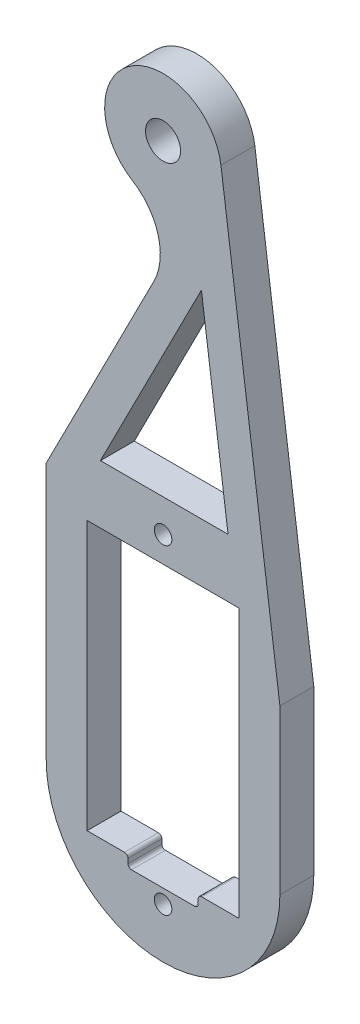
from build123d import *

# Parameters (mm, degrees)
SKETCH_1_R          = 0.75
SKETCH_1_W          = 13
SKETCH_1_H          = 23
SKETCH_1_R_2        = 1.5
EXTRUDE_1_DEPTH     = 1.45
SKETCH_2_W          = 6
SKETCH_2_H          = 1
CUT_EXTRUDE_1_DEPTH = 3
FILLET_1_R          = 0.3


with BuildPart() as part:
    # 草图1 → 凸台-拉伸1 (new body, symmetric)
    with BuildSketch(Plane.XY):
        with BuildLine():
            ThreePointArc((-10, -8), (0, -18), (10, -8))
            Line((10, -8), (10, 6))
            Line((10, 6), (4.955472685, 43.54580062))
            ThreePointArc((4.955472685, 43.54580062), (-2.725773115, 47.071677579), (-2.618575221, 38.62053245))
            ThreePointArc((-2.618575221, 38.62053245), (-0.423906888, 35.714832413), (-0.782117822, 32.091112401))
            Line((-0.782117822, 32.091112401), (-10, 14))
            Line((-10, 14), (-10, -8))
        make_face()
        with Locations((0, -13.7)):
            Circle(SKETCH_1_R, mode=Mode.SUBTRACT)
        Rectangle(SKETCH_1_W, SKETCH_1_H, mode=Mode.SUBTRACT)
        with Locations((0, 13.7)):
            Circle(SKETCH_1_R, mode=Mode.SUBTRACT)
        with Locations((0, 42.88)):
            Circle(SKETCH_1_R_2, mode=Mode.SUBTRACT)
        Polygon((5.562298916, 16.5), (-5.359207663, 16.5), (3.283346167, 33.461966942), align=None, mode=Mode.SUBTRACT)
    extrude(amount=EXTRUDE_1_DEPTH, both=True)

    # 草图2 → 切除-拉伸1 (cut)
    with BuildSketch(Plane.XY.offset(1.45)):
        with Locations((0, -12)):
            Rectangle(SKETCH_2_W, SKETCH_2_H)
    extrude(amount=-CUT_EXTRUDE_1_DEPTH, mode=Mode.SUBTRACT)

    # 圆角1
    fillet_1_edges = [part.edges().sort_by_distance(p)[0] for p in [
        (-3, -11.5, 0),
        (3, -11.5, 0),
        (3, -12.5, 0),
        (-3, -12.5, 0),
    ]]
    fillet(fillet_1_edges, radius=FILLET_1_R)


solid = part.part
